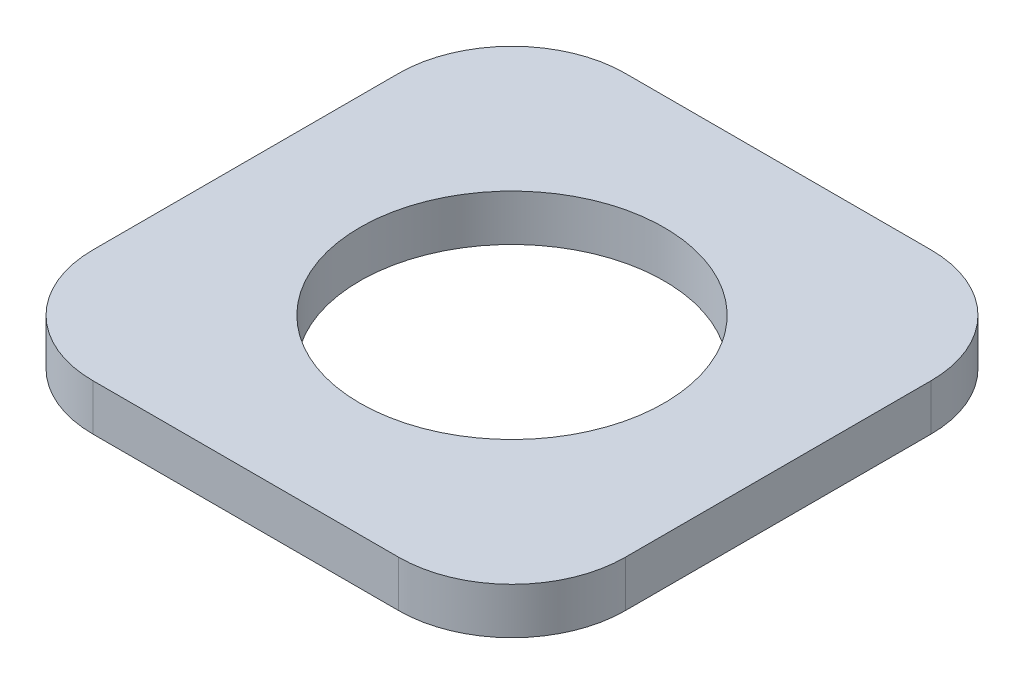
from build123d import *

# Parameters (mm, degrees)
CROQUIS1_W              = 93.98
CROQUIS1_H              = 93.98
SALIENTE_EXTRUIR1_DEPTH = 8.1661
CROQUIS2_R              = 26.8605
CORTAR_EXTRUIR1_DEPTH   = 8.1661
REDONDEO1_R             = 20


with BuildPart() as part:
    # Croquis1 → Saliente-Extruir1 (new body)
    with BuildSketch(Plane(origin=(0, 0, 0), x_dir=(1, 0, 0), z_dir=(0, 1, 0))):
        Rectangle(CROQUIS1_W, CROQUIS1_H)
    extrude(amount=SALIENTE_EXTRUIR1_DEPTH)

    # Croquis2 → Cortar-Extruir1 (cut)
    with BuildSketch(Plane(origin=(0, 8.1661, 0), x_dir=(1, 0, 0), z_dir=(0, 1, 0))):
        Circle(CROQUIS2_R)
    extrude(amount=-CORTAR_EXTRUIR1_DEPTH, mode=Mode.SUBTRACT)

    # Redondeo1
    redondeo1_edges = [part.edges().sort_by_distance(p)[0] for p in [
        (46.99, 4.08305, 46.99),
        (-46.99, 4.08305, 46.99),
        (-46.99, 4.08305, -46.99),
        (46.99, 4.08305, -46.99),
    ]]
    fillet(redondeo1_edges, radius=REDONDEO1_R)


solid = part.part
